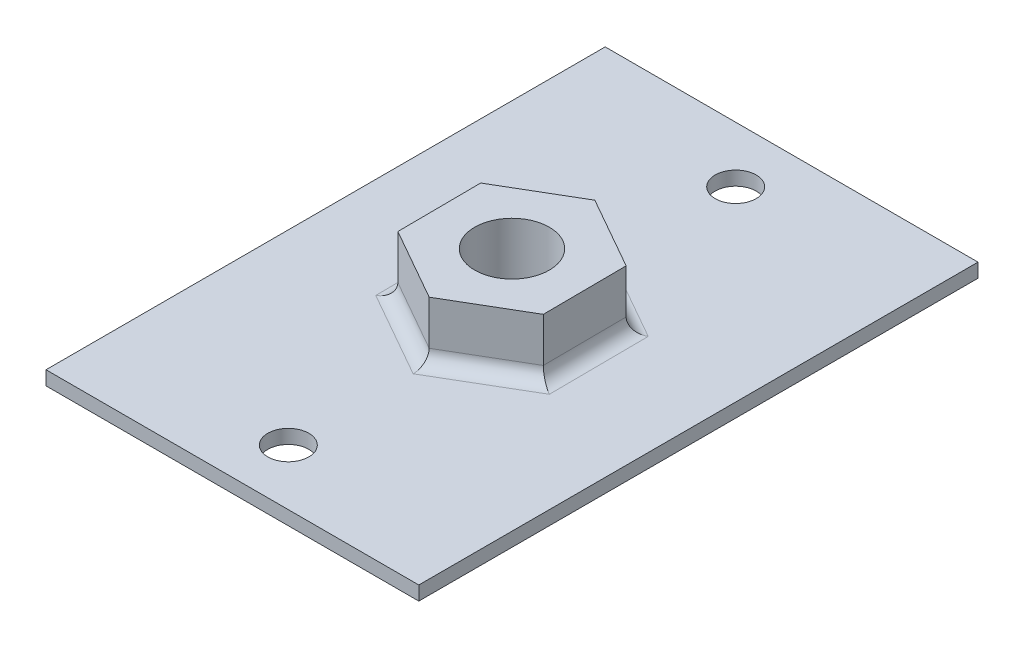
from build123d import *

# Parameters (mm, degrees)
SKETCH1_R      = 2
EXTRUDE1_DEPTH = 3.125
SKETCH2_R      = 1.1
EXTRUDE2_DEPTH = 0.75
FILLET1_R      = 0.75


with BuildPart() as part:
    # Sketch1 → Extrude1 (new body)
    with BuildSketch(Plane(origin=(0, 0, 0), x_dir=(1, 0, 0), z_dir=(0, 1, 0))):
        Polygon((3.859462612, 2.263930582), (-0.030890091, 4.474357958), (-3.890352703, 2.210427376), (-3.859462612, -2.263930582), (0.030890091, -4.474357958), (3.890352703, -2.210427376), align=None)
        with Locations(Location((0, 0, 0), (0, 0, 270))):  # turned: the seam where the file's is
            Circle(SKETCH1_R, mode=Mode.SUBTRACT)
    extrude(amount=EXTRUDE1_DEPTH)

    # Sketch2 → Extrude2 (add)
    with BuildSketch(Plane.XZ):
        Polygon((10, 0), (10, -15), (-10, -15), (-10, 15), (10, 15), align=None)
        with Locations(Location((0, -12, 0), (0, 0, 270))):  # turned: the seam where the file's is
            Circle(SKETCH2_R, mode=Mode.SUBTRACT)
        with Locations(Location((0, 12, 0), (0, 0, 90))):  # turned: the seam where the file's is
            Circle(SKETCH2_R, mode=Mode.SUBTRACT)
    extrude(amount=EXTRUDE2_DEPTH)

    # Fillet1
    fillet1_edges = [part.edges().sort_by_distance(p)[0] for p in [
        (1.960621397, 0, 3.342392667),
        (-1.91428626, 0, 3.36914427),
        (-3.874907657, 0, 0.026751603),
        (-1.960621397, 0, -3.342392667),
        (1.91428626, 0, -3.36914427),
        (3.874907657, 0, -0.026751603),
    ]]
    fillet(fillet1_edges, radius=FILLET1_R)


solid = part.part
